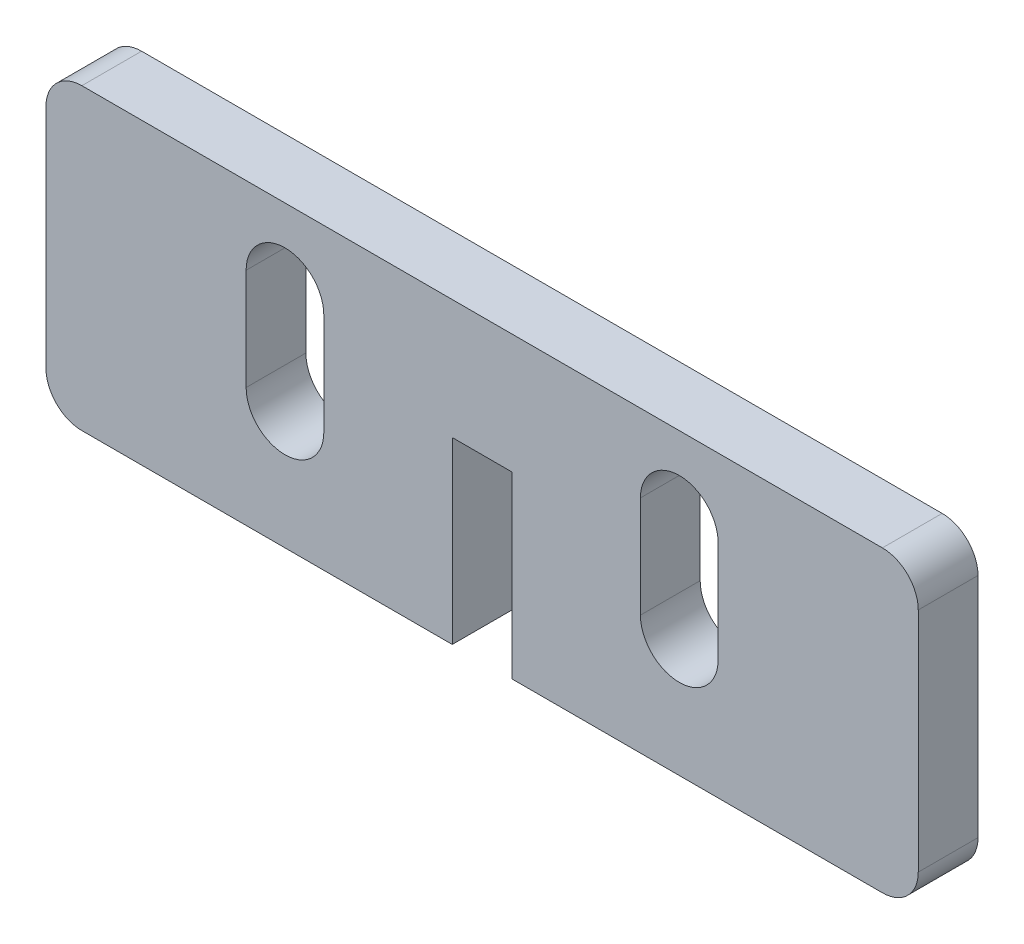
from build123d import *

# Parameters (mm, degrees)
EXTRUDE_1_DEPTH = 5


with BuildPart() as part:
    # 草图1 → 凸台-拉伸1 (new body)
    with BuildSketch(Plane.XY):
        with BuildLine():
            Line((36.5, -9.5), (36.5, 9.5))
            ThreePointArc((36.5, 9.5), (35.621320344, 11.621320344), (33.5, 12.5))
            Line((33.5, 12.5), (-33.5, 12.5))
            ThreePointArc((-33.5, 12.5), (-35.621320344, 11.621320344), (-36.5, 9.5))
            Line((-36.5, 9.5), (-36.5, -9.5))
            ThreePointArc((-36.5, -9.5), (-35.621320344, -11.621320344), (-33.5, -12.5))
            Line((-33.5, -12.5), (-2.5, -12.5))
            Line((-2.5, -12.5), (-2.5, 2.5))
            Line((-2.5, 2.5), (2.5, 2.5))
            Line((2.5, 2.5), (2.5, -12.5))
            Line((2.5, -12.5), (33.5, -12.5))
            ThreePointArc((33.5, -12.5), (35.621320344, -11.621320344), (36.5, -9.5))
        make_face()
        with BuildLine():
            Line((-19.75, -2.5), (-19.75, 6))
            ThreePointArc((-19.75, 6), (-16.5, 9.25), (-13.25, 6))
            Line((-13.25, 6), (-13.25, -2.5))
            ThreePointArc((-13.25, -2.5), (-16.5, -5.75), (-19.75, -2.5))
        make_face(mode=Mode.SUBTRACT)
        with BuildLine():
            Line((19.75, -2.5), (19.75, 6))
            ThreePointArc((19.75, 6), (16.5, 9.25), (13.25, 6))
            Line((13.25, 6), (13.25, -2.5))
            ThreePointArc((13.25, -2.5), (16.5, -5.75), (19.75, -2.5))
        make_face(mode=Mode.SUBTRACT)
    extrude(amount=EXTRUDE_1_DEPTH)


solid = part.part
